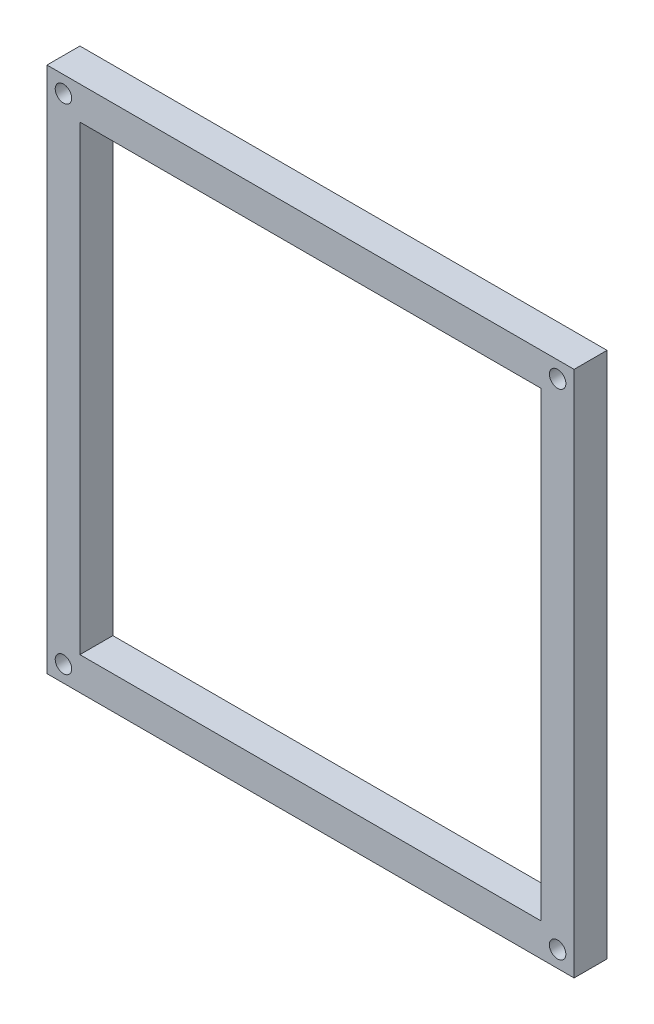
from build123d import *

# Parameters (mm, degrees)
CROQUIS2_W                   = 160
CROQUIS2_H                   = 160
CROQUIS2_W_2                 = 140
CROQUIS2_H_2                 = 140
SALIENTE_EXTRUIR1_DEPTH      = 10
SALIENTE_EXTRUIR2_DEPTH      = 140
SALIENTE_EXTRUIR2_DEPTH_BACK = 10
CROQUIS4_W                   = 10
CROQUIS4_H                   = 10
CROQUIS7_W                   = 160
CROQUIS7_H                   = 160
CROQUIS7_W_2                 = 140
CROQUIS7_H_2                 = 140
SALIENTE_EXTRUIR3_DEPTH      = 10
CROQUIS8_W                   = 63
CROQUIS8_H                   = 12
CROQUIS8_R                   = 2.5
SALIENTE_EXTRUIR4_DEPTH      = 5
CROQUIS9_W                   = 174.167702824
CROQUIS9_H                   = 180.53552259
CORTAR_EXTRUIR2_DEPTH        = 278.128129211
CROQUIS10_R                  = 2.5
CORTAR_EXTRUIR3_DEPTH        = 4


with BuildPart() as part:
    # Croquis2 → Saliente-Extruir1 (new body)
    with BuildSketch(Plane.XY):
        with Locations((80, -80)):
            Rectangle(CROQUIS2_W, CROQUIS2_H)
        with Locations((80, -80)):
            Rectangle(CROQUIS2_W_2, CROQUIS2_H_2, mode=Mode.SUBTRACT)
    extrude(amount=SALIENTE_EXTRUIR1_DEPTH)

    # Croquis4 → Saliente-Extruir2 (add, two sides: drawn at the far end of the back side and taken through both)
    with BuildSketch(Plane.XY.offset(10).offset(-SALIENTE_EXTRUIR2_DEPTH_BACK)):
        with Locations((5, -5)):
            Rectangle(CROQUIS4_W, CROQUIS4_H)
        with Locations((155, -5)):
            Rectangle(CROQUIS4_W, CROQUIS4_H)
        with Locations((155, -155)):
            Rectangle(CROQUIS4_W, CROQUIS4_H)
        with Locations((5, -155)):
            Rectangle(CROQUIS4_W, CROQUIS4_H)
    extrude(amount=SALIENTE_EXTRUIR2_DEPTH + SALIENTE_EXTRUIR2_DEPTH_BACK)

    # Croquis7 → Saliente-Extruir3 (add)
    with BuildSketch(Plane.XY.offset(150)):
        with Locations((80, -80)):
            Rectangle(CROQUIS7_W, CROQUIS7_H)
        with Locations((80, -80)):
            Rectangle(CROQUIS7_W_2, CROQUIS7_H_2, mode=Mode.SUBTRACT)
    extrude(amount=SALIENTE_EXTRUIR3_DEPTH)

    # Croquis8 → Saliente-Extruir4 (add)
    # profile 1 of 2: a face of its own
    with BuildSketch(Plane.XY.offset(160)):
        with Locations((31.5, -80)):
            Rectangle(CROQUIS8_W, CROQUIS8_H)
        with Locations((55, -80)):
            Circle(CROQUIS8_R, mode=Mode.SUBTRACT)
    # profile 2 of 2: a face of its own
    with BuildSketch(Plane.XY.offset(160)):
        with Locations((128.5, -80)):
            Rectangle(CROQUIS8_W, CROQUIS8_H)
        with Locations((105, -80)):
            Circle(CROQUIS8_R, mode=Mode.SUBTRACT)
    extrude(amount=-SALIENTE_EXTRUIR4_DEPTH)

    # Croquis9 → Cortar-Extruir2 (cut, through all)
    with BuildSketch(Plane.ZY):
        with Locations((97.083851412, -84.953806067)):
            Rectangle(CROQUIS9_W, CROQUIS9_H)
    extrude(amount=-CORTAR_EXTRUIR2_DEPTH, mode=Mode.SUBTRACT)

    # Croquis10 → Cortar-Extruir3 (cut)
    with BuildSketch(Plane.XY.offset(10)):
        with Locations((5, -155)):
            Circle(CROQUIS10_R)
        with Locations((5, -5)):
            Circle(CROQUIS10_R)
        with Locations((155, -5)):
            Circle(CROQUIS10_R)
        with Locations((155, -155)):
            Circle(CROQUIS10_R)
    extrude(amount=-CORTAR_EXTRUIR3_DEPTH, mode=Mode.SUBTRACT)


solid = part.part
